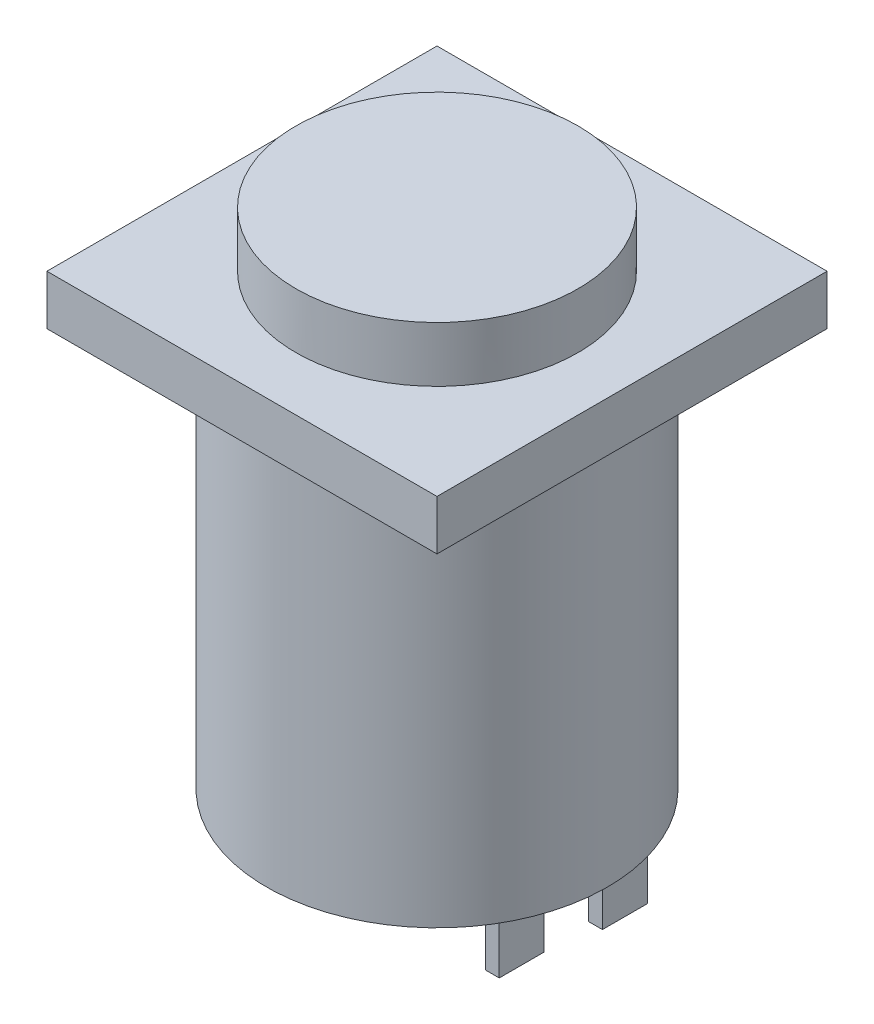
from build123d import *

# Parameters (mm, degrees)
SKETCH1_W           = 17.907
SKETCH1_H           = 17.907
BOSS_EXTRUDE1_DEPTH = 2.286
SKETCH2_R           = 6.477
BOSS_EXTRUDE2_DEPTH = 2.54
SKETCH3_R           = 7.8232
BOSS_EXTRUDE3_DEPTH = 18.288
SKETCH4_W           = 0.635
SKETCH4_H           = 2.0574
BOSS_EXTRUDE4_DEPTH = 6.096


with BuildPart() as part:
    # Sketch1 → Boss-Extrude1 (new body)
    with BuildSketch(Plane(origin=(0, 0, 0), x_dir=(1, 0, 0), z_dir=(0, 1, 0))):
        Rectangle(SKETCH1_W, SKETCH1_H)
    extrude(amount=BOSS_EXTRUDE1_DEPTH)

    # Sketch2 → Boss-Extrude2 (add)
    with BuildSketch(Plane(origin=(0, 2.286, 0), x_dir=(1, 0, 0), z_dir=(0, 1, 0))):
        with Locations(Location((0, 0, 0), (0, 0, 90))):  # turned: the seam where the file's is
            Circle(SKETCH2_R)
    extrude(amount=BOSS_EXTRUDE2_DEPTH)

    # Sketch3 → Boss-Extrude3 (add)
    with BuildSketch(Plane.XZ):
        with Locations(Location((0, 0, 0), (0, 0, 270))):  # turned: the seam where the file's is
            Circle(SKETCH3_R)
    extrude(amount=BOSS_EXTRUDE3_DEPTH)

    # Sketch4 → Boss-Extrude4 (add)
    with BuildSketch(Plane.XZ.offset(18.288)):
        with Locations((-2.54, -1.0287)):
            Rectangle(SKETCH4_W, SKETCH4_H)
        with Locations((2.54, -1.0287)):
            Rectangle(SKETCH4_W, SKETCH4_H)
        with Locations((-2.9845, -5.3213)):
            Rectangle(SKETCH4_W, SKETCH4_H)
        with Locations((2.9845, -5.3213)):
            Rectangle(SKETCH4_W, SKETCH4_H)
    extrude(amount=BOSS_EXTRUDE4_DEPTH)


solid = part.part
